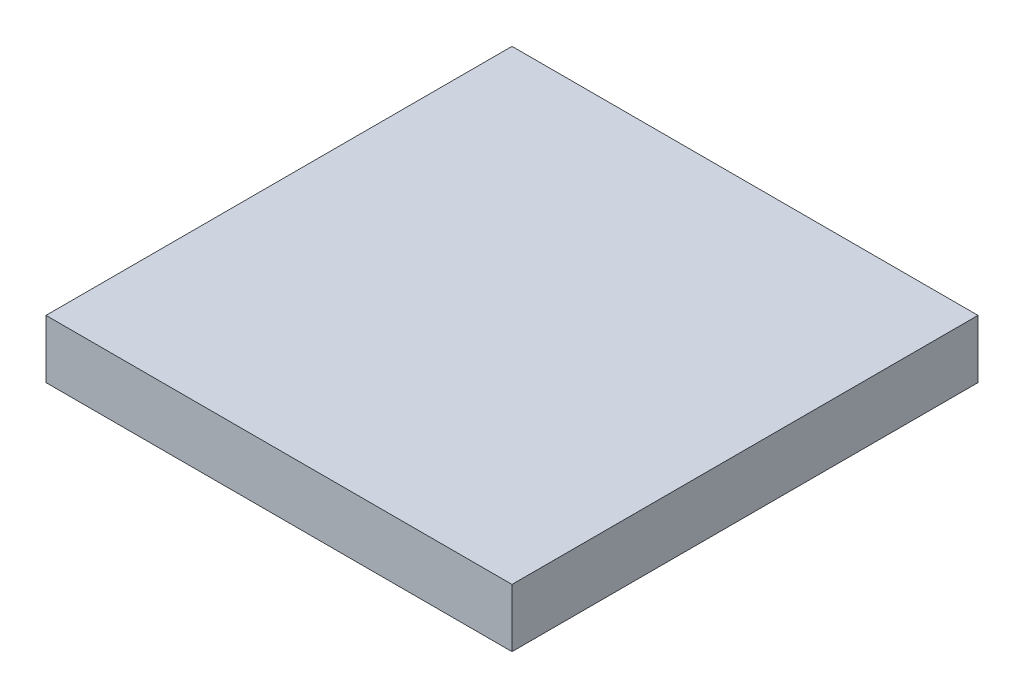
from build123d import *

# Parameters (mm, degrees)
SKETCH1_W           = 8
SKETCH1_H           = 8
BOSS_EXTRUDE1_DEPTH = 1


with BuildPart() as part:
    # Sketch1 → Boss-Extrude1 (new body)
    with BuildSketch(Plane(origin=(0, 0, 0), x_dir=(1, 0, 0), z_dir=(0, 1, 0))):
        with Locations((4, 4)):
            Rectangle(SKETCH1_W, SKETCH1_H)
    extrude(amount=BOSS_EXTRUDE1_DEPTH)


solid = part.part
